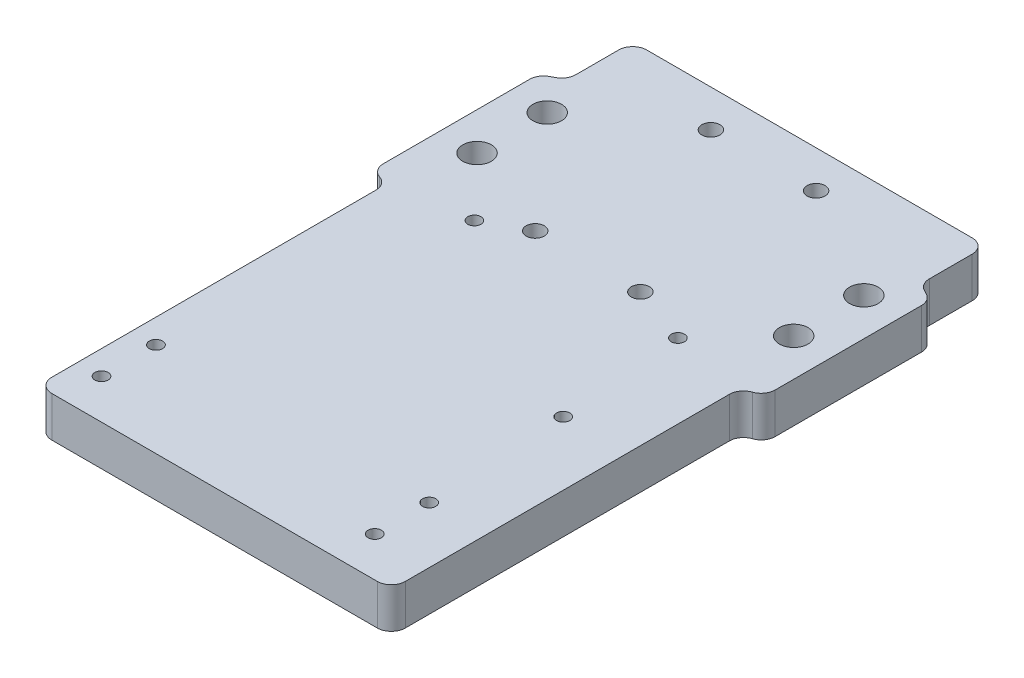
from build123d import *

# Parameters (mm, degrees)
SKETCH1_W                                         = 70.945719932
SKETCH1_H                                         = 127
BOSS_EXTRUDE1_DEPTH                               = 7.3152
F_6_0_204_DIAMETER_HOLE1_D                        = 5.1816
FILLET1_R                                         = 2.54
CUT_EXTRUDE1_START                                = -8.3152
CUT_EXTRUDE1_DEPTH                                = 9.3152
FILLET2_R                                         = 2.54
MIRROR5_START                                     = -8.3152
MIRROR5_COPY_1_DEPTH                              = 9.3152
FILLET2_OF_MIRROR5_R                              = 2.54
SKETCH7_W                                         = 3.464842272
SKETCH7_H                                         = 58.764649847
SKETCH7_H_2                                       = 60.549907821
CUT_EXTRUDE4_DEPTH                                = 8.3152
FILLET4_R                                         = 2.54
FILLET5_R                                         = 2.54
FILLET6_R                                         = 2.54
FILLET7_R                                         = 2.54
SKETCH8_W                                         = 77.149558558
SKETCH8_H                                         = 21.523608728
CUT_EXTRUDE5_DEPTH                                = 8.3152001
FILLET8_R                                         = 2.54
FILLET9_R                                         = 2.54
CSK_FOR_4_FLAT_HEAD_SOCKET_CAP_SCREW1_D           = 3.2639
CSK_FOR_4_FLAT_HEAD_SOCKET_CAP_SCREW1_CSINK_D     = 6.477
CSK_FOR_4_FLAT_HEAD_SOCKET_CAP_SCREW1_CSINK_ANGLE = 82
M2_CLEARANCE_HOLE1_D                              = 2.4
M2_CLEARANCE_HOLE1_DEPTH                          = 7.3152


with BuildPart() as part:
    # Sketch1 → Boss-Extrude1 (new body)
    with BuildSketch(Plane(origin=(0, 0, 0), x_dir=(1, 0, 0), z_dir=(0, 1, 0))):
        Rectangle(SKETCH1_W, SKETCH1_H)
    extrude(amount=BOSS_EXTRUDE1_DEPTH)

    # 6 _0.204_ Diameter Hole1 (through all)
    with Locations(Plane(origin=(-28.662459966, 7.3152, -12.7), x_dir=(0, 0, 1), z_dir=(0, 1, 0))):
        with Locations((0, 0), (-12.7, 0)):
            f_6_0_204_diameter_hole1 = Hole(F_6_0_204_DIAMETER_HOLE1_D / 2)

    # Mirror2: 6 _0.204_ Diameter Hole1 across plane
    add(f_6_0_204_diameter_hole1.mirror(Plane(origin=(0, 0, 0), x_dir=(0, 0, 1), z_dir=(1, 0, 0))), mode=Mode.SUBTRACT)

    # Fillet1
    fillet1_edges = [part.edges().sort_by_distance(p)[0] for p in [
        (-35.472859966, 3.6576, -63.5),
        (35.472859966, 3.6576, -63.5),
        (35.472859966, 3.6576, 63.5),
        (-35.472859966, 3.6576, 63.5),
    ]]
    fillet(fillet1_edges, radius=FILLET1_R)

    # Sketch4 → Cut-Extrude1 (cut)
    with BuildSketch(Plane(origin=(0, 7.3152, 0), x_dir=(1, 0, 0), z_dir=(0, 1, 0)).offset(CUT_EXTRUDE1_START)):
        Polygon((-35.472859966, 30.558892356), (-32.008017694, 32.360224767), (-32.008017694, 63.5), (-35.472859966, 63.5), align=None)
    cut_extrude1 = extrude(amount=CUT_EXTRUDE1_DEPTH, mode=Mode.SUBTRACT)

    # Mirror4: Cut-Extrude1 across plane
    add(cut_extrude1.mirror(Plane(origin=(0, 0, 0), x_dir=(0, 0, 1), z_dir=(1, 0, 0))), mode=Mode.SUBTRACT)

    # Fillet2
    fillet2_edges = [part.edges().sort_by_distance(p)[0] for p in [
        (-35.472859966, 3.6576, -30.558892356),
        (-32.008017694, 3.6576, -32.360224767),
        (35.472859966, 3.6576, -30.558892356),
        (32.008017694, 3.6576, -32.360224767),
    ]]
    fillet(fillet2_edges, radius=FILLET2_R)

    # Mirror5: Cut-Extrude1 across plane
    add(cut_extrude1.mirror(Plane.XY), mode=Mode.SUBTRACT)

    # Mirror5 copy 1 sketch → Mirror5 copy 1 (cut)
    with BuildSketch(Plane(origin=(0, 7.3152, 0), x_dir=(-1, 0, 0), z_dir=(0, 1, 0)).offset(MIRROR5_START)):
        Polygon((-35.472859966, 30.558892356), (-32.008017694, 32.360224767), (-32.008017694, 63.5), (-35.472859966, 63.5), align=None)
    extrude(amount=MIRROR5_COPY_1_DEPTH, mode=Mode.SUBTRACT)

    # Fillet2 of Mirror5
    fillet2_of_mirror5_edges = [part.edges().sort_by_distance(p)[0] for p in [
        (-35.472859966, 3.6576, 30.558892356),
        (-32.008017694, 3.6576, 32.360224767),
        (35.472859966, 3.6576, 30.558892356),
        (32.008017694, 3.6576, 32.360224767),
    ]]
    fillet(fillet2_of_mirror5_edges, radius=FILLET2_OF_MIRROR5_R)

    # Sketch7 → Cut-Extrude4 (cut, through all)
    with BuildSketch(Plane(origin=(0, 7.3152, 0), x_dir=(1, 0, 0), z_dir=(0, 1, 0))):
        with Locations((-33.74043883, -29.382324924)):
            Rectangle(SKETCH7_W, SKETCH7_H)
        with Locations((33.74043883, -30.274953911)):
            Rectangle(SKETCH7_W, SKETCH7_H_2)
    extrude(amount=-CUT_EXTRUDE4_DEPTH, mode=Mode.SUBTRACT)

    # Fillet4
    fillet4_edges = [part.edges().sort_by_distance(p)[0] for p in [
        (-35.472859966, 3.6576, 0),
    ]]
    fillet(fillet4_edges, radius=FILLET4_R)

    # Fillet5
    fillet5_edges = [part.edges().sort_by_distance(p)[0] for p in [
        (-32.008017694, 3.6576, 0),
    ]]
    fillet(fillet5_edges, radius=FILLET5_R)

    # Fillet6
    fillet6_edges = [part.edges().sort_by_distance(p)[0] for p in [
        (35.472859966, 3.6576, 0),
    ]]
    fillet(fillet6_edges, radius=FILLET6_R)

    # Fillet7
    fillet7_edges = [part.edges().sort_by_distance(p)[0] for p in [
        (32.008017694, 3.6576, 0),
    ]]
    fillet(fillet7_edges, radius=FILLET7_R)

    # Sketch8 → Cut-Extrude5 (cut, through all)
    with BuildSketch(Plane(origin=(0, 7.3152, 0), x_dir=(1, 0, 0), z_dir=(0, 1, 0))):
        with Locations((0.713956222, 54.980140586)):
            Rectangle(SKETCH8_W, SKETCH8_H)
    extrude(amount=-CUT_EXTRUDE5_DEPTH, mode=Mode.SUBTRACT)

    # Fillet8
    fillet8_edges = [part.edges().sort_by_distance(p)[0] for p in [
        (32.008017694, 3.6576, -44.218336222),
        (-32.008017694, 3.6576, -44.218336222),
    ]]
    fillet(fillet8_edges, radius=FILLET8_R)

    # Fillet9
    fillet9_edges = [part.edges().sort_by_distance(p)[0] for p in [
        (-32.008017694, 3.6576, 63.5),
        (32.008017694, 3.6576, 63.5),
    ]]
    fillet(fillet9_edges, radius=FILLET9_R)

    # CSK for _4 Flat Head Socket Cap Screw1 (through all)
    with Locations(Plane(origin=(0, 0, 0), x_dir=(-1, 0, 0), z_dir=(0, -1, 0))):
        with Locations((-7.886782562, 5.715853783), (11.187183143, 5.749267318), (-7.942426048, 37.470798372), (11.13154387, 37.504218179)):
            CounterSinkHole(CSK_FOR_4_FLAT_HEAD_SOCKET_CAP_SCREW1_D / 2, CSK_FOR_4_FLAT_HEAD_SOCKET_CAP_SCREW1_CSINK_D / 2, counter_sink_angle=CSK_FOR_4_FLAT_HEAD_SOCKET_CAP_SCREW1_CSINK_ANGLE)

    # M2 Clearance Hole1
    with Locations(Plane(origin=(0, 7.3152, 0), x_dir=(1, 0, 0), z_dir=(0, 1, 0))):
        with Locations((-18.334377313, 1.881276897), (18.512582442, 1.881276897), (20.480957082, -20.858204931), (-27.663655127, -46.443938456), (-27.663655127, -56.298290006), (21.805189655, -56.298290006), (21.805189655, -46.443938456)):
            Hole(M2_CLEARANCE_HOLE1_D / 2, depth=M2_CLEARANCE_HOLE1_DEPTH)


solid = part.part
